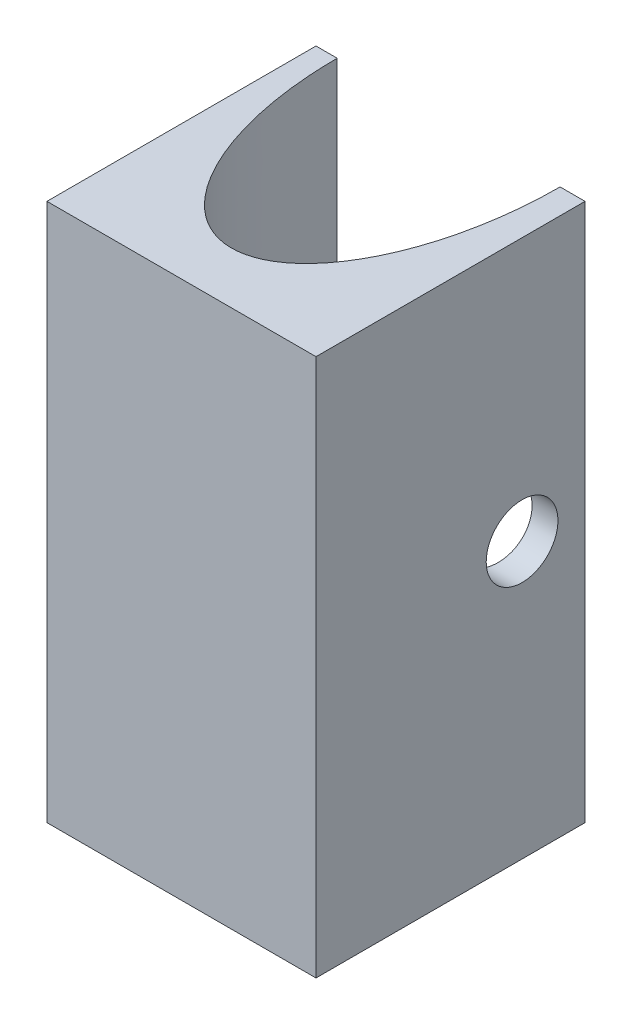
from build123d import *

# Parameters (mm, degrees)
SKETCH1_W           = 15
SKETCH1_H           = 15
BOSS_EXTRUDE1_DEPTH = 30
SKETCH2_RX          = 12.112533461
SKETCH2_RY          = 6.212800173
CUT_EXTRUDE3_DEPTH  = 30
SKETCH3_R           = 2
CUT_EXTRUDE4_DEPTH  = 30


with BuildPart() as part:
    # Sketch1 → Boss-Extrude1 (new body)
    with BuildSketch(Plane(origin=(0, 0, 0), x_dir=(1, 0, 0), z_dir=(0, 1, 0))):
        with Locations((-41.148219583, -26.628215269)):
            Rectangle(SKETCH1_W, SKETCH1_H)
    extrude(amount=BOSS_EXTRUDE1_DEPTH)

    # Sketch2 → Cut-Extrude3 (cut)
    with BuildSketch(Plane(origin=(0, 0, 0), x_dir=(-1, 0, 0), z_dir=(0, -1, 0))):
        with Locations(Location((41.252812179, -19.128215269), (0, 0, -90))):
            Ellipse(SKETCH2_RX, SKETCH2_RY)
    extrude(amount=-CUT_EXTRUDE3_DEPTH, mode=Mode.SUBTRACT)

    # Sketch3 → Cut-Extrude4 (cut)
    with BuildSketch(Plane.ZY.offset(48.648219583)):
        with Locations((22.639015202, 15.346006291)):
            Circle(SKETCH3_R)
    extrude(amount=-CUT_EXTRUDE4_DEPTH, mode=Mode.SUBTRACT)


solid = part.part
